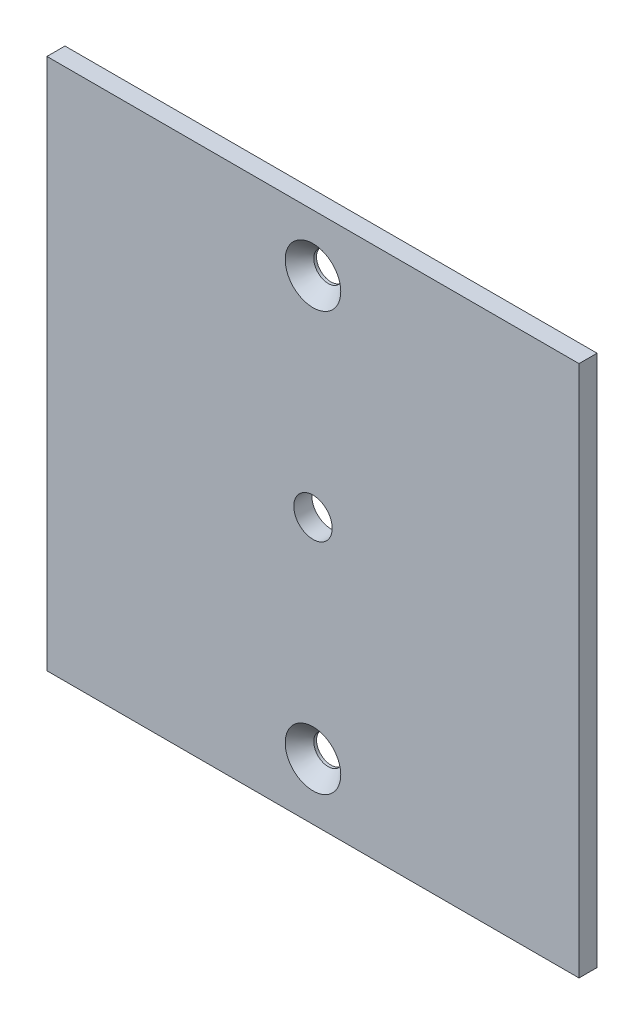
from build123d import *

# Parameters (mm, degrees)
SKETCH1_W                                       = 93.649999898
SKETCH1_H                                       = 93.649999898
BOSS_EXTRUDE1_DEPTH                             = 3.175
F_1_4_CLEARANCE_HOLE1_D                         = 6.7564
F_1_4_CLEARANCE_HOLE1_DEPTH                     = 4.826
F_1_4_CLEARANCE_HOLE1_TIP                       = 2.029827343
CSK_FOR_10_FLAT_HEAD_MACHINE_SCREW1_D           = 5.1054
CSK_FOR_10_FLAT_HEAD_MACHINE_SCREW1_DEPTH       = 4.826
CSK_FOR_10_FLAT_HEAD_MACHINE_SCREW1_CSINK_D     = 9.779
CSK_FOR_10_FLAT_HEAD_MACHINE_SCREW1_CSINK_ANGLE = 82
CSK_FOR_10_FLAT_HEAD_MACHINE_SCREW1_TIP         = 1.533816902


with BuildPart() as part:
    # Sketch1 → Boss-Extrude1 (new body)
    with BuildSketch(Plane.XY):
        Rectangle(SKETCH1_W, SKETCH1_H)
    extrude(amount=BOSS_EXTRUDE1_DEPTH)

    # 1/4 Clearance Hole1
    with Locations(Plane.XY.offset(3.175)):
        with Locations((0, 0)):
            Hole(F_1_4_CLEARANCE_HOLE1_D / 2, depth=F_1_4_CLEARANCE_HOLE1_DEPTH)
            with Locations((0, 0, -(F_1_4_CLEARANCE_HOLE1_DEPTH + F_1_4_CLEARANCE_HOLE1_TIP / 2))):  # 118° drill point
                Cone(0, F_1_4_CLEARANCE_HOLE1_D / 2, F_1_4_CLEARANCE_HOLE1_TIP, mode=Mode.SUBTRACT)

    # CSK for #10 Flat Head Machine Screw1
    with Locations(Plane.XY.offset(3.175)):
        with Locations((0, 36.824999949), (0, -36.824999949)):
            CounterSinkHole(CSK_FOR_10_FLAT_HEAD_MACHINE_SCREW1_D / 2, CSK_FOR_10_FLAT_HEAD_MACHINE_SCREW1_CSINK_D / 2, depth=CSK_FOR_10_FLAT_HEAD_MACHINE_SCREW1_DEPTH, counter_sink_angle=CSK_FOR_10_FLAT_HEAD_MACHINE_SCREW1_CSINK_ANGLE)
            with Locations((0, 0, -(CSK_FOR_10_FLAT_HEAD_MACHINE_SCREW1_DEPTH + CSK_FOR_10_FLAT_HEAD_MACHINE_SCREW1_TIP / 2))):  # 118° drill point
                Cone(0, CSK_FOR_10_FLAT_HEAD_MACHINE_SCREW1_D / 2, CSK_FOR_10_FLAT_HEAD_MACHINE_SCREW1_TIP, mode=Mode.SUBTRACT)


solid = part.part
